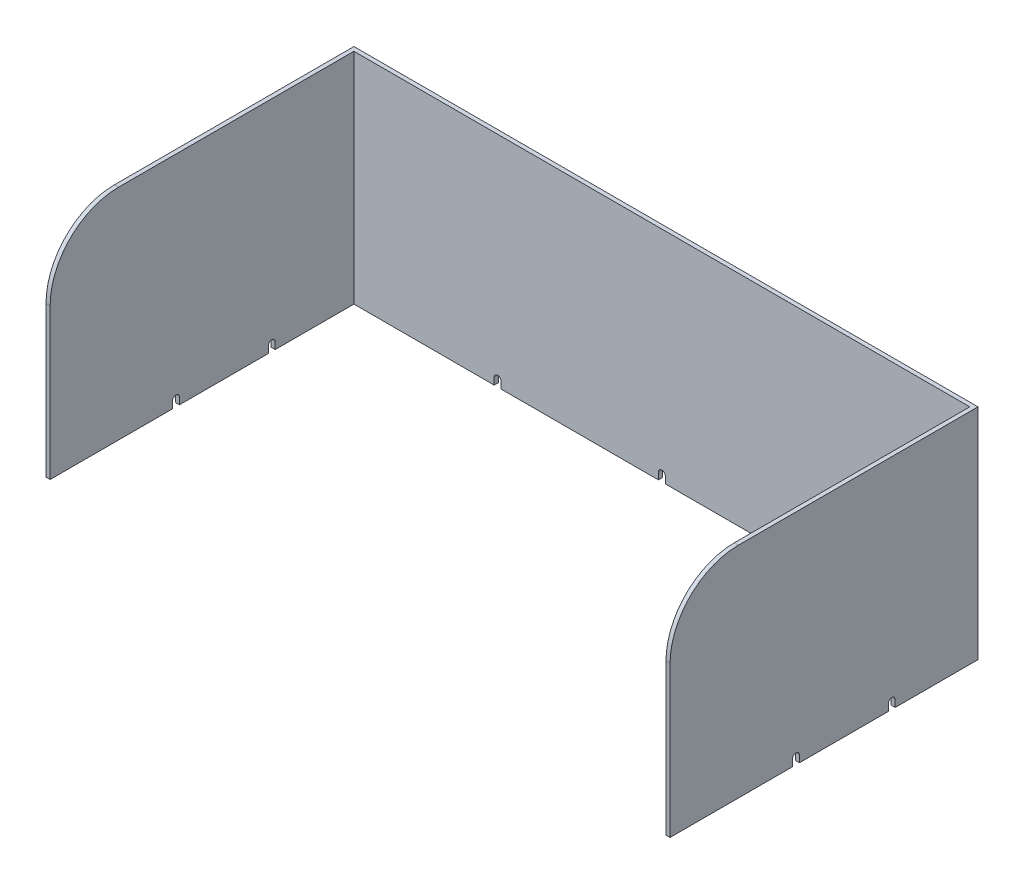
from build123d import *

# Parameters (mm, degrees)
SALIENTE_EXTRUIR1_DEPTH = 160
CORTAR_EXTRUIR1_DEPTH   = 456
CORTAR_EXTRUIR2_REACH   = 227
CROQUIS3_R              = 2.5
CROQUIS3_W              = 5
CROQUIS3_H              = 5
REDONDEO1_R             = 50


with BuildPart() as part:
    # Croquis1 → Saliente-Extruir1 (new body)
    with BuildSketch(Plane(origin=(0, 0, 0), x_dir=(1, 0, 0), z_dir=(0, 1, 0))):
        Polygon((3, -225), (3, -3), (453, -3), (453, -225), (456, -225), (456, 0), (0, 0), (0, -225), align=None)
    extrude(amount=SALIENTE_EXTRUIR1_DEPTH)

    # Croquis2 → Cortar-Extruir1 (cut)
    with BuildSketch(Plane.ZY):
        with BuildLine():
            ThreePointArc((65.5, 5), (63, 2.5), (60.5, 5))
            Line((60.5, 5), (60.5, 0))
            Line((60.5, 0), (65.5, 0))
            Line((65.5, 0), (65.5, 5))
        make_face()
        with BuildLine():
            ThreePointArc((65.5, 5), (63, 7.5), (60.5, 5))
            Line((60.5, 5), (65.5, 5))
        make_face()
        with BuildLine():
            Line((65.5, 5), (60.5, 5))
            ThreePointArc((60.5, 5), (63, 2.5), (65.5, 5))
        make_face()
        with BuildLine():
            ThreePointArc((135.5, 5), (133, 7.5), (130.5, 5))
            Line((130.5, 5), (135.5, 5))
        make_face()
        with BuildLine():
            Line((135.5, 5), (130.5, 5))
            ThreePointArc((130.5, 5), (133, 2.5), (135.5, 5))
        make_face()
        with BuildLine():
            Line((130.5, 5), (130.5, 0))
            Line((130.5, 0), (135.5, 0))
            Line((135.5, 0), (135.5, 5))
            ThreePointArc((135.5, 5), (133, 2.5), (130.5, 5))
        make_face()
    extrude(amount=-CORTAR_EXTRUIR1_DEPTH, mode=Mode.SUBTRACT)

    # Croquis3 → Cortar-Extruir2 (cut, up to next)
    with BuildSketch(Plane(origin=(0, 0, 0), x_dir=(-1, 0, 0), z_dir=(0, 0, -1)), mode=Mode.PRIVATE) as cortar_extruir2_sk1:
        with Locations((-348, 5)):
            Circle(CROQUIS3_R)
    cortar_extruir2_tool1 = extrude(cortar_extruir2_sk1.sketch, amount=-CORTAR_EXTRUIR2_REACH, mode=Mode.PRIVATE) & part.part
    add(cortar_extruir2_tool1.solids().sort_by_distance((348, 5, 0))[0], mode=Mode.SUBTRACT)
    # Croquis3 → Cortar-Extruir2 (cut, up to next)
    with BuildSketch(Plane(origin=(0, 0, 0), x_dir=(-1, 0, 0), z_dir=(0, 0, -1)), mode=Mode.PRIVATE) as cortar_extruir2_sk2:
        with Locations((-228, 5)):
            Circle(CROQUIS3_R)
    cortar_extruir2_tool2 = extrude(cortar_extruir2_sk2.sketch, amount=-CORTAR_EXTRUIR2_REACH, mode=Mode.PRIVATE) & part.part
    add(cortar_extruir2_tool2.solids().sort_by_distance((228, 5, 0))[0], mode=Mode.SUBTRACT)
    # Croquis3 → Cortar-Extruir2 (cut, up to next)
    with BuildSketch(Plane(origin=(0, 0, 0), x_dir=(-1, 0, 0), z_dir=(0, 0, -1)), mode=Mode.PRIVATE) as cortar_extruir2_sk3:
        with Locations((-108, 5)):
            Circle(CROQUIS3_R)
    cortar_extruir2_tool3 = extrude(cortar_extruir2_sk3.sketch, amount=-CORTAR_EXTRUIR2_REACH, mode=Mode.PRIVATE) & part.part
    add(cortar_extruir2_tool3.solids().sort_by_distance((108, 5, 0))[0], mode=Mode.SUBTRACT)
    # Croquis3 → Cortar-Extruir2 (cut, up to next)
    with BuildSketch(Plane(origin=(0, 0, 0), x_dir=(-1, 0, 0), z_dir=(0, 0, -1)), mode=Mode.PRIVATE) as cortar_extruir2_sk4:
        with Locations((-228, 2.5)):
            Rectangle(CROQUIS3_W, CROQUIS3_H)
    cortar_extruir2_tool4 = extrude(cortar_extruir2_sk4.sketch, amount=-CORTAR_EXTRUIR2_REACH, mode=Mode.PRIVATE) & part.part
    add(cortar_extruir2_tool4.solids().sort_by_distance((228, 2.5, 0))[0], mode=Mode.SUBTRACT)
    # Croquis3 → Cortar-Extruir2 (cut, up to next)
    with BuildSketch(Plane(origin=(0, 0, 0), x_dir=(-1, 0, 0), z_dir=(0, 0, -1)), mode=Mode.PRIVATE) as cortar_extruir2_sk5:
        with Locations((-108, 2.5)):
            Rectangle(CROQUIS3_W, CROQUIS3_H)
    cortar_extruir2_tool5 = extrude(cortar_extruir2_sk5.sketch, amount=-CORTAR_EXTRUIR2_REACH, mode=Mode.PRIVATE) & part.part
    add(cortar_extruir2_tool5.solids().sort_by_distance((108, 2.5, 0))[0], mode=Mode.SUBTRACT)
    # Croquis3 → Cortar-Extruir2 (cut, up to next)
    with BuildSketch(Plane(origin=(0, 0, 0), x_dir=(-1, 0, 0), z_dir=(0, 0, -1)), mode=Mode.PRIVATE) as cortar_extruir2_sk6:
        with Locations((-348, 2.5)):
            Rectangle(CROQUIS3_W, CROQUIS3_H)
    cortar_extruir2_tool6 = extrude(cortar_extruir2_sk6.sketch, amount=-CORTAR_EXTRUIR2_REACH, mode=Mode.PRIVATE) & part.part
    add(cortar_extruir2_tool6.solids().sort_by_distance((348, 2.5, 0))[0], mode=Mode.SUBTRACT)

    # Redondeo1
    redondeo1_edges = [part.edges().sort_by_distance(p)[0] for p in [
        (454.5, 160, 225),
        (1.5, 160, 225),
    ]]
    fillet(redondeo1_edges, radius=REDONDEO1_R)


solid = part.part
